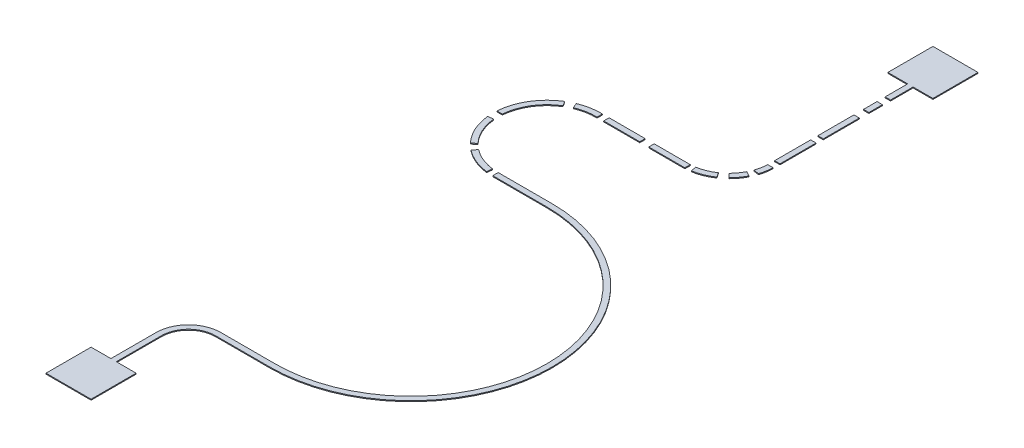
from build123d import *

# Parameters (mm, degrees)
SKETCH1_W              = 250
SKETCH1_H              = 250
BOSS_EXTRUDE1_DEPTH    = 5
SKETCH2_W              = 30
SKETCH2_H              = 250
BOSS_EXTRUDE2_DEPTH    = 5
BOSS_EXTRUDE3_DEPTH    = 5
SKETCH7_W              = 300
SKETCH7_H              = 30
BOSS_EXTRUDE4_DEPTH    = 5
BOSS_EXTRUDE5_DEPTH    = 5
SKETCH10_W             = 300
SKETCH10_H             = 30
BOSS_EXTRUDE6_DEPTH    = 5
BOSS_EXTRUDE7_DEPTH    = 5
BOSS_EXTRUDE7_2_DEPTH  = 5
BOSS_EXTRUDE7_3_DEPTH  = 5
BOSS_EXTRUDE7_4_DEPTH  = 5
SKETCH12_W             = 200
SKETCH12_H             = 30
BOSS_EXTRUDE8_DEPTH    = 5
BOSS_EXTRUDE8_2_DEPTH  = 5
BOSS_EXTRUDE9_DEPTH    = 5
BOSS_EXTRUDE9_2_DEPTH  = 5
BOSS_EXTRUDE9_3_DEPTH  = 5
SKETCH14_W             = 30
SKETCH14_H             = 200
BOSS_EXTRUDE10_DEPTH   = 5
BOSS_EXTRUDE10_2_DEPTH = 5
SKETCH14_H_2           = 75
BOSS_EXTRUDE10_3_DEPTH = 5
BOSS_EXTRUDE10_4_DEPTH = 5


with BuildPart() as part:
    # Sketch1 → Boss-Extrude1 (new body)
    with BuildSketch(Plane(origin=(0, 0, 0), x_dir=(1, 0, 0), z_dir=(0, 1, 0))):
        with Locations((21.103896104, 38.961038961)):
            Rectangle(SKETCH1_W, SKETCH1_H)
    extrude(amount=BOSS_EXTRUDE1_DEPTH)



with BuildPart() as body_2:
    # Sketch2 → Boss-Extrude2 (new body)
    with BuildSketch(Plane(origin=(0, 5, 0), x_dir=(1, 0, 0), z_dir=(0, 1, 0))):
        with Locations((21.103896104, 288.961038961)):
            Rectangle(SKETCH2_W, SKETCH2_H)
    extrude(amount=-BOSS_EXTRUDE2_DEPTH)

    # Sketch6 → Boss-Extrude3 (add)
    with BuildSketch(Plane(origin=(0, 0, 0), x_dir=(1, 0, 0), z_dir=(0, 1, 0))):
        with BuildLine():
            Line((186.372355095, 594.229497953), (186.372355095, 564.229497953))
            ThreePointArc((186.372355095, 564.229497953), (80.116508744, 520.216885312), (36.103896104, 413.961038961))
            Line((36.103896104, 413.961038961), (6.103896104, 413.961038961))
            ThreePointArc((6.103896104, 413.961038961), (58.903305308, 541.430088748), (186.372355095, 594.229497953))
        make_face()
    extrude(amount=BOSS_EXTRUDE3_DEPTH)

    # Sketch7 → Boss-Extrude4 (add)
    with BuildSketch(Plane(origin=(0, 0, 0), x_dir=(1, 0, 0), z_dir=(0, 1, 0))):
        with Locations((336.372355095, 579.229497953)):
            Rectangle(SKETCH7_W, SKETCH7_H)
    extrude(amount=BOSS_EXTRUDE4_DEPTH)


with BuildPart() as part_1:
    add(part.part)

    add(body_2.part)  # Boss-Extrude5 merges body 2
    # Sketch8 → Boss-Extrude5 (add)
    with BuildSketch(Plane(origin=(0, 0, 0), x_dir=(1, 0, 0), z_dir=(0, 1, 0))):
        with BuildLine():
            Line((486.372355095, 2131.607057749), (486.372355095, 2101.607057749))
            ThreePointArc((486.372355095, 2101.607057749), (1240.061134994, 1347.918277851), (486.372355095, 594.229497953))
            Line((486.372355095, 594.229497953), (186.372355095, 594.229497953))
            ThreePointArc((186.372355095, 594.229497953), (58.903305308, 541.430088748), (6.103896104, 413.961038961))
            Line((6.103896104, 413.961038961), (6.103896104, 163.961038961))
            Line((6.103896104, 163.961038961), (36.103896104, 163.961038961))
            Line((36.103896104, 163.961038961), (36.103896104, 413.961038961))
            ThreePointArc((36.103896104, 413.961038961), (80.116508744, 520.216885312), (186.372355095, 564.229497953))
            Line((186.372355095, 564.229497953), (486.372355095, 564.229497953))
            ThreePointArc((486.372355095, 564.229497953), (1270.061134994, 1347.918277851), (486.372355095, 2131.607057749))
        make_face()
    extrude(amount=BOSS_EXTRUDE5_DEPTH)

    # Sketch10 → Boss-Extrude6 (add)
    with BuildSketch(Plane(origin=(0, 0, 0), x_dir=(1, 0, 0), z_dir=(0, 1, 0))):
        with Locations((336.372355095, 2116.608277851)):
            Rectangle(SKETCH10_W, SKETCH10_H)
    extrude(amount=BOSS_EXTRUDE6_DEPTH)


with BuildPart() as body_2_2:
    # Sketch11 → Boss-Extrude7 (new body)
    with BuildSketch(Plane(origin=(0, 0, 0), x_dir=(1, 0, 0), z_dir=(0, 1, 0))):
        with BuildLine():
            Line((194.138193135, 2672.13994615), (194.138193135, 2702.151095344))
            ThreePointArc((194.138193135, 2702.151095344), (131.681935279, 2697.229802428), (71.605683596, 2679.457710455))
            Line((71.605683596, 2679.457710455), (83.070060163, 2651.7346502))
            ThreePointArc((83.070060163, 2651.7346502), (137.526703553, 2667.801823345), (194.138193135, 2672.13994615))
        make_face()
    extrude(amount=BOSS_EXTRUDE7_DEPTH)


with BuildPart() as body_3:
    # Sketch11 → Boss-Extrude7 2 (new body)
    with BuildSketch(Plane(origin=(0, 0, 0), x_dir=(1, 0, 0), z_dir=(0, 1, 0))):
        with BuildLine():
            Line((44.964556313, 2632.315689233), (29.271272289, 2657.883654278))
            ThreePointArc((29.271272289, 2657.883654278), (-70.112980729, 2558.161610757), (-113.129498421, 2424.104552318))
            Line((-113.129498421, 2424.104552318), (-83.038229419, 2424.104552318))
            ThreePointArc((-83.038229419, 2424.104552318), (-43.912046021, 2543.502751874), (44.964556313, 2632.315689233))
        make_face()
    extrude(amount=BOSS_EXTRUDE7_2_DEPTH)


with BuildPart() as body_4:
    # Sketch11 → Boss-Extrude7 3 (new body)
    with BuildSketch(Plane(origin=(0, 0, 0), x_dir=(1, 0, 0), z_dir=(0, 1, 0))):
        with BuildLine():
            Line((-82.66072222, 2375.567393394), (-112.51772113, 2372.641711242))
            ThreePointArc((-112.51772113, 2372.641711242), (-86.881851845, 2277.329681582), (-31.732320704, 2195.475481892))
            Line((-31.732320704, 2195.475481892), (-9.945210372, 2216.098813907))
            ThreePointArc((-9.945210372, 2216.098813907), (-59.585694469, 2289.776359551), (-82.66072222, 2375.567393394))
        make_face()
    extrude(amount=BOSS_EXTRUDE7_3_DEPTH)


with BuildPart() as body_5:
    # Sketch11 → Boss-Extrude7 4 (new body)
    with BuildSketch(Plane(origin=(0, 0, 0), x_dir=(1, 0, 0), z_dir=(0, 1, 0))):
        with BuildLine():
            Line((21.713850904, 2187.543901905), (3.44022883, 2163.751576749))
            ThreePointArc((3.44022883, 2163.751576749), (72.481138399, 2124.041671747), (149.53232629, 2103.876399771))
            Line((149.53232629, 2103.876399771), (153.212383901, 2133.649830476))
            ThreePointArc((153.212383901, 2133.649830476), (83.85806324, 2151.800734793), (21.713850904, 2187.543901905))
        make_face()
    extrude(amount=BOSS_EXTRUDE7_4_DEPTH)


with BuildPart() as body_6:
    # Sketch12 → Boss-Extrude8 (new body)
    with BuildSketch(Plane(origin=(0, 0, 0), x_dir=(1, 0, 0), z_dir=(0, 1, 0))):
        with Locations((331.138193135, 2687.249898038)):
            Rectangle(SKETCH12_W, SKETCH12_H)
    extrude(amount=BOSS_EXTRUDE8_DEPTH)


with BuildPart() as body_7:
    # Sketch12 → Boss-Extrude8 2 (new body)
    with BuildSketch(Plane(origin=(0, 0, 0), x_dir=(1, 0, 0), z_dir=(0, 1, 0))):
        with Locations((581.138193135, 2687.249898038)):
            Rectangle(SKETCH12_W, SKETCH12_H)
    extrude(amount=BOSS_EXTRUDE8_2_DEPTH)


with BuildPart() as body_8:
    # Sketch13 → Boss-Extrude9 (new body)
    with BuildSketch(Plane(origin=(0, 0, 0), x_dir=(1, 0, 0), z_dir=(0, 1, 0))):
        with BuildLine():
            Line((814.524837295, 2716.186900912), (797.676028873, 2740.97663625))
            ThreePointArc((797.676028873, 2740.97663625), (755.085921794, 2718.281057155), (708.638465423, 2705.179899646))
            Line((708.638465423, 2705.179899646), (713.637920847, 2675.626240501))
            ThreePointArc((713.637920847, 2675.626240501), (766.266726809, 2690.470934491), (814.524837295, 2716.186900912))
        make_face()
    extrude(amount=BOSS_EXTRUDE9_DEPTH)


with BuildPart() as body_9:
    # Sketch13 → Boss-Extrude9 2 (new body)
    with BuildSketch(Plane(origin=(0, 0, 0), x_dir=(1, 0, 0), z_dir=(0, 1, 0))):
        with BuildLine():
            Line((898.093524537, 2810.684387291), (871.967165315, 2825.42933062))
            ThreePointArc((871.967165315, 2825.42933062), (853.424296595, 2795.060872341), (830.330084802, 2767.99172717))
            Line((830.330084802, 2767.99172717), (851.524580826, 2746.797231146))
            ThreePointArc((851.524580826, 2746.797231146), (877.298037122, 2776.926526297), (898.093524537, 2810.684387291))
        make_face()
    extrude(amount=BOSS_EXTRUDE9_2_DEPTH)


with BuildPart() as body_10:
    # Sketch13 → Boss-Extrude9 3 (new body)
    with BuildSketch(Plane(origin=(0, 0, 0), x_dir=(1, 0, 0), z_dir=(0, 1, 0))):
        with BuildLine():
            Line((926.071913934, 2917.183618837), (896.071913934, 2917.183618837))
            ThreePointArc((896.071913934, 2917.183618837), (892.203801963, 2884.506266075), (883.615550676, 2852.74129144))
            Line((883.615550676, 2852.74129144), (913.615550676, 2847.884198566))
            ThreePointArc((913.615550676, 2847.884198566), (922.245200786, 2882.102251934), (926.071913934, 2917.183618837))
        make_face()
    extrude(amount=BOSS_EXTRUDE9_3_DEPTH)


with BuildPart() as body_11:
    # Sketch14 → Boss-Extrude10 (new body)
    with BuildSketch(Plane(origin=(0, 0, 0), x_dir=(1, 0, 0), z_dir=(0, 1, 0))):
        with Locations((911.071913934, 3055.131798486)):
            Rectangle(SKETCH14_W, SKETCH14_H)
    extrude(amount=BOSS_EXTRUDE10_DEPTH)


with BuildPart() as body_12:
    # Sketch14 → Boss-Extrude10 2 (new body)
    with BuildSketch(Plane(origin=(0, 0, 0), x_dir=(1, 0, 0), z_dir=(0, 1, 0))):
        with Locations((911.071913934, 3295.131798486)):
            Rectangle(SKETCH14_W, SKETCH14_H)
    extrude(amount=BOSS_EXTRUDE10_2_DEPTH)


with BuildPart() as body_13:
    # Sketch14 → Boss-Extrude10 3 (new body)
    with BuildSketch(Plane(origin=(0, 0, 0), x_dir=(1, 0, 0), z_dir=(0, 1, 0))):
        with Locations((911.071913934, 3485.711929371)):
            Rectangle(SKETCH14_W, SKETCH14_H_2)
    extrude(amount=BOSS_EXTRUDE10_3_DEPTH)


with BuildPart() as body_14:
    # Sketch14 → Boss-Extrude10 4 (new body)
    with BuildSketch(Plane(origin=(0, 0, 0), x_dir=(1, 0, 0), z_dir=(0, 1, 0))):
        Polygon((896.071913934, 3568.211929371), (926.071913934, 3568.211929371), (926.071913934, 3693.211929371), (1036.071913934, 3693.211929371), (1036.071913934, 3943.211929371), (786.071913934, 3943.211929371), (786.071913934, 3693.211929371), (896.071913934, 3693.211929371), align=None)
    extrude(amount=BOSS_EXTRUDE10_4_DEPTH)


solid = Compound([part_1.part, body_2_2.part, body_3.part, body_4.part, body_5.part, body_6.part, body_7.part, body_8.part, body_9.part, body_10.part, body_11.part, body_12.part, body_13.part, body_14.part])
